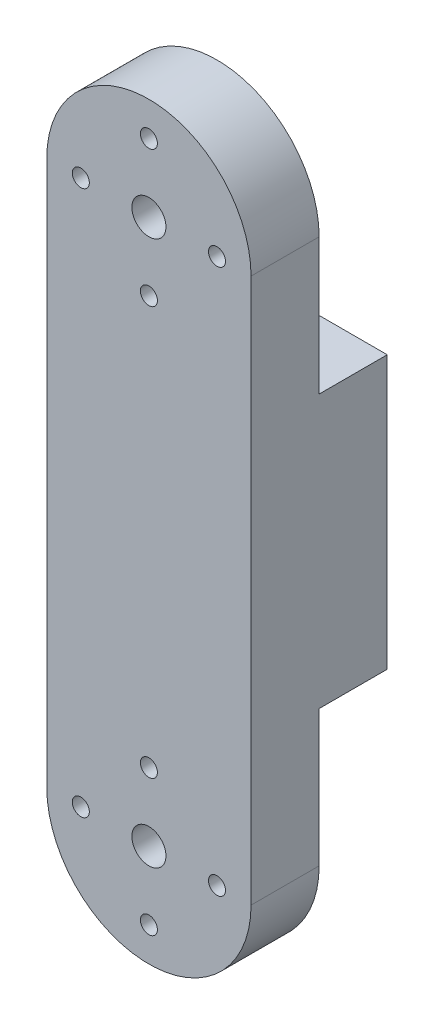
from build123d import *

# Parameters (mm, degrees)
SKETCH1_R           = 3.175
SKETCH1_R_2         = 1.5875
BOSS_EXTRUDE1_DEPTH = 25.4
CUT_EXTRUDE1_REACH  = 40.1
SKETCH2_W           = 12.7
SKETCH2_H           = 44.45


with BuildPart() as part:
    # Sketch1 → Boss-Extrude1 (new body)
    with BuildSketch(Plane.XY):
        with BuildLine():
            Line((-19.05, 50.8), (-19.05, -50.8))
            ThreePointArc((-19.05, -50.8), (0, -69.85), (19.05, -50.8))
            Line((19.05, -50.8), (19.05, 50.8))
            ThreePointArc((19.05, 50.8), (0, 69.85), (-19.05, 50.8))
        make_face()
        with Locations((0, 50.8)):
            Circle(SKETCH1_R, mode=Mode.SUBTRACT)
        with Locations((0, -50.8)):
            Circle(SKETCH1_R, mode=Mode.SUBTRACT)
        with Locations((0, 63.5)):
            Circle(SKETCH1_R_2, mode=Mode.SUBTRACT)
        with Locations((-12.7, 50.8)):
            Circle(SKETCH1_R_2, mode=Mode.SUBTRACT)
        with Locations((0, 38.1)):
            Circle(SKETCH1_R_2, mode=Mode.SUBTRACT)
        with Locations((12.7, 50.8)):
            Circle(SKETCH1_R_2, mode=Mode.SUBTRACT)
        with Locations((-12.7, -50.8)):
            Circle(SKETCH1_R_2, mode=Mode.SUBTRACT)
        with Locations((0, -38.1)):
            Circle(SKETCH1_R_2, mode=Mode.SUBTRACT)
        with Locations((12.7, -50.8)):
            Circle(SKETCH1_R_2, mode=Mode.SUBTRACT)
        with Locations((0, -63.5)):
            Circle(SKETCH1_R_2, mode=Mode.SUBTRACT)
    extrude(amount=BOSS_EXTRUDE1_DEPTH)

    # Sketch2 → Cut-Extrude1 (cut, up to next)
    with BuildSketch(Plane(origin=(19.05, 0, 0), x_dir=(0, 0, -1), z_dir=(1, 0, 0)), mode=Mode.PRIVATE) as cut_extrude1_sk1:
        with Locations((-6.35, 47.625)):
            Rectangle(SKETCH2_W, SKETCH2_H)
    cut_extrude1_tool1 = extrude(cut_extrude1_sk1.sketch, amount=-CUT_EXTRUDE1_REACH, mode=Mode.PRIVATE) & part.part
    add(cut_extrude1_tool1.solids().sort_by_distance((19.05, 47.625, 6.35))[0], mode=Mode.SUBTRACT)
    # Sketch2 → Cut-Extrude1 (cut, up to next)
    with BuildSketch(Plane(origin=(19.05, 0, 0), x_dir=(0, 0, -1), z_dir=(1, 0, 0)), mode=Mode.PRIVATE) as cut_extrude1_sk2:
        with Locations((-6.35, -47.625)):
            Rectangle(SKETCH2_W, SKETCH2_H)
    cut_extrude1_tool2 = extrude(cut_extrude1_sk2.sketch, amount=-CUT_EXTRUDE1_REACH, mode=Mode.PRIVATE) & part.part
    add(cut_extrude1_tool2.solids().sort_by_distance((19.05, -47.625, 6.35))[0], mode=Mode.SUBTRACT)


solid = part.part
